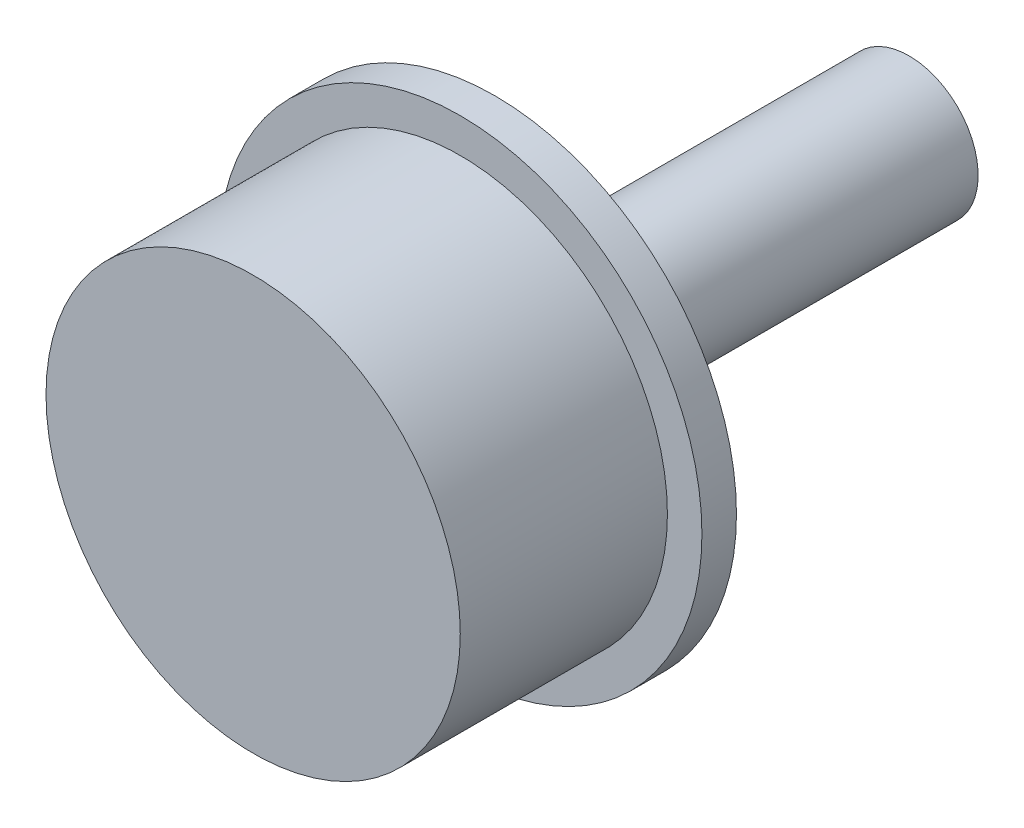
from build123d import *


with BuildPart() as part:
    # Skizze1 → Rotation1 (revolve)
    with BuildSketch(Plane(origin=(0, 0, 0), x_dir=(0, 0, -1), z_dir=(1, 0, 0))):
        Polygon((4, 1), (4, 0), (-4, 0), (-3, 1), align=None)
    revolve(axis=Axis((0, 0, 0), (0, 0, 1)))

    # Skizze2 → Rotation2 (revolve)
    with BuildSketch(Plane(origin=(0, 0, 0), x_dir=(0, 0, -1), z_dir=(1, 0, 0))):
        Polygon((-2.5, 3), (-5.5, 3), (-5.5, 0), (-2, 0), (-2, 3.5), (-2.5, 3.5), align=None)
    revolve(axis=Axis((0, 0, 2), (0, 0, -1)))


solid = part.part
